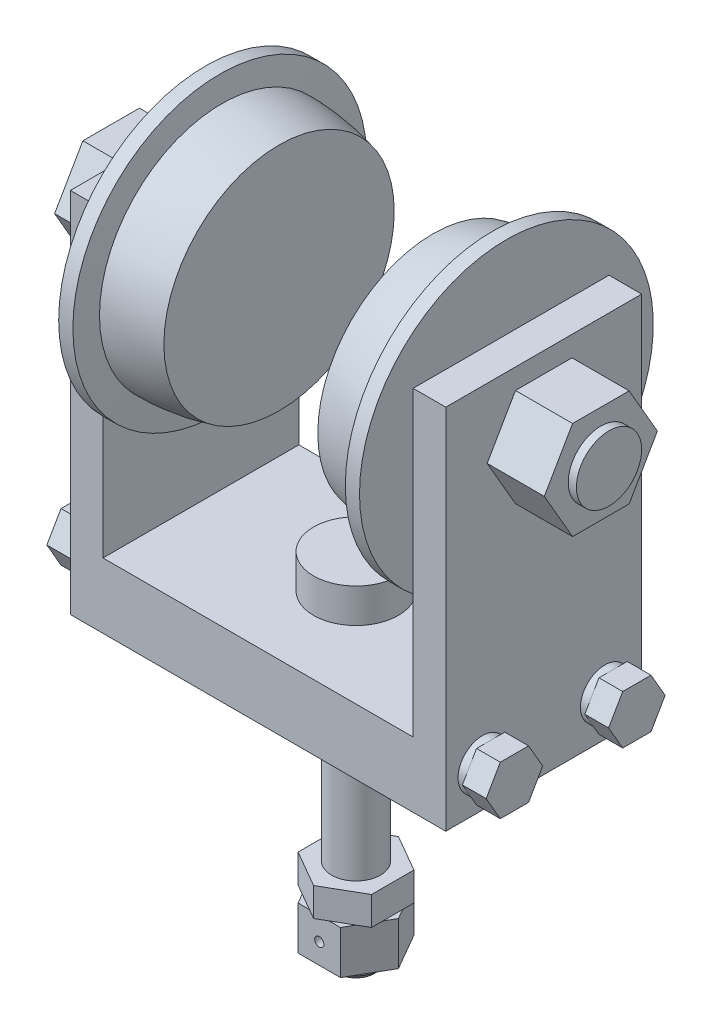
from build123d import *

# Parameters (mm, degrees)
YOKE_CROSS_SECTION_W           = 76.2
YOKE_CROSS_SECTION_H           = 25.4
YOKE_DEPTH                     = 60.325
SIDEPLATE_PROFILE_W            = 76.2
SIDEPLATE_PROFILE_H            = 142.875
SIDEPLATE_DEPTH                = 12.7
WHEEL_PIN_NUT_DEPTH            = 22.225
WHEEL_PIN_PROJECTION_PROFILE_R = 12.7
WHEEL_PIN_PROJECTION_DEPTH     = 3.175
LOCKNUTS_PROFILE_R             = 9.525
LOCKNUTS_DEPTH                 = 3.175
SCREWS_DEPTH                   = 9.2456
PROFILE_R                      = 16.4973
KING_BOLT_HEAD_DEPTH           = 13.3096
DIA_R                          = 9.525
KING_BOLT_DEPTH                = 65.589601
KING_BOLT_JAM_NUT_DEPTH        = 11.1125
KING_BOLT_NUT_DEPTH            = 16.891
SKETCH5_R                      = 9.525
EXTENDED_KING_BOLT_DEPTH       = 6.35
CHAMFER1_SIZE                  = 2.38125
COTTER_PIN_HOLE_REACH          = 73.437
SKETCH8_R                      = 1.778


with BuildPart() as part:
    # YOKE CROSS SECTION → YOKE (new body)
    with BuildSketch(Plane(origin=(0, 0, 0), x_dir=(0, 0, -1), z_dir=(1, 0, 0))):
        with Locations((0, 12.7)):
            Rectangle(YOKE_CROSS_SECTION_W, YOKE_CROSS_SECTION_H)
    extrude(amount=YOKE_DEPTH)

    # SIDEPLATE PROFILE → SIDEPLATE (add)
    with BuildSketch(Plane(origin=(60.325, 0, 0), x_dir=(0, 0, -1), z_dir=(1, 0, 0))):
        with Locations((0, 71.4375)):
            Rectangle(SIDEPLATE_PROFILE_W, SIDEPLATE_PROFILE_H)
    extrude(amount=SIDEPLATE_DEPTH)

    # WHEEL PIN NUT PROFILE → WHEEL PIN NUT (add)
    with BuildSketch(Plane(origin=(73.025, 0, 0), x_dir=(0, 0, -1), z_dir=(1, 0, 0))):
        Polygon((21.997045256, 115.8875), (10.998522628, 134.9375), (-10.998522628, 134.9375), (-21.997045256, 115.8875), (-10.998522628, 96.8375), (10.998522628, 96.8375), align=None)
    extrude(amount=WHEEL_PIN_NUT_DEPTH)

    # WHEEL PIN PROJECTION PROFILE → WHEEL PIN PROJECTION (add)
    with BuildSketch(Plane(origin=(95.25, 0, 0), x_dir=(0, 0, -1), z_dir=(1, 0, 0))):
        with Locations((0, 115.8875)):
            Circle(WHEEL_PIN_PROJECTION_PROFILE_R)
    extrude(amount=WHEEL_PIN_PROJECTION_DEPTH)

    # LOCKNUTS PROFILE → LOCKNUTS (add)
    with BuildSketch(Plane(origin=(73.025, 0, 0), x_dir=(0, 0, -1), z_dir=(1, 0, 0))):
        with Locations((-23.8125, 15.563196315)):
            Circle(LOCKNUTS_PROFILE_R)
    locknuts = extrude(amount=LOCKNUTS_DEPTH)

    # SCREWS PROFILE → SCREWS (add)
    with BuildSketch(Plane(origin=(76.2, 0, 0), x_dir=(0, 0, -1), z_dir=(1, 0, 0))):
        Polygon((-12.813977372, 15.563196315), (-18.313238686, 25.088196315), (-29.311761314, 25.088196315), (-34.811022628, 15.563196315), (-29.311761314, 6.038196315), (-18.313238686, 6.038196315), align=None)
    screws = extrude(amount=SCREWS_DEPTH)

    # PROFILE → KING BOLT HEAD (add)
    with BuildSketch(Plane(origin=(0, 25.4, 0), x_dir=(-1, 0, 0), z_dir=(0, 1, 0))):
        with Locations(Location((0, 0, 0), (0, 0, 90))):  # turned: the seam where the file's is
            Circle(PROFILE_R)
    extrude(amount=KING_BOLT_HEAD_DEPTH)

    # Mirror1: LOCKNUTS, SCREWS across plane
    add(locknuts.mirror(Plane.XY))
    add(screws.mirror(Plane.XY))

    # Mirror5: part across plane


with BuildPart() as part_1:
    add(part.part)
    add(part.part.mirror(Plane(origin=(0, 0, 0), x_dir=(0, 0, 1), z_dir=(1, 0, 0))))

    # DIA. → KING BOLT (add)
    with BuildSketch(Plane.XZ):
        with Locations(Location((0, 0, 0), (0, 0, 90))):  # turned: the seam where the file's is
            Circle(DIA_R)
    extrude(amount=KING_BOLT_DEPTH)

    # KING BOLT JAN NUT PROFILE → KING BOLT JAM NUT (add)
    with BuildSketch(Plane.XZ.offset(65.589600888)):
        Polygon((0, -16.497783942), (14.2875, -8.248891971), (14.2875, 8.248891971), (0, 16.497783942), (-14.2875, 8.248891971), (-14.2875, -8.248891971), align=None)
    extrude(amount=KING_BOLT_JAM_NUT_DEPTH)

    # KING BOLT NUT PROFILE → KING BOLT NUT (add)
    with BuildSketch(Plane.XZ.offset(76.702100888)):
        Polygon((16.497783942, 0), (8.248891971, 14.2875), (-8.248891971, 14.2875), (-16.497783942, 0), (-8.248891971, -14.2875), (8.248891971, -14.2875), align=None)
    extrude(amount=KING_BOLT_NUT_DEPTH)

    # Sketch5 → EXTENDED KING BOLT (add)
    with BuildSketch(Plane.XZ.offset(93.593100888)):
        with Locations(Location((0, 0, 0), (0, 0, 90))):  # turned: the seam where the file's is
            Circle(SKETCH5_R)
    extrude(amount=EXTENDED_KING_BOLT_DEPTH)

    # Chamfer1
    chamfer1_edges = [part_1.edges().sort_by_distance(p)[0] for p in [
        (0, -99.943100888, -9.525),
    ]]
    chamfer(chamfer1_edges, length=CHAMFER1_SIZE)

    # Sketch7 → WHEEL (revolve)
    with BuildSketch(Plane.XY, mode=Mode.PRIVATE) as wheel_sk:
        with BuildLine():
            Line((29.93325323, 160.689554869), (29.93325323, 115.8875))
            Line((29.93325323, 115.8875), (60.325, 115.8875))
            Line((60.325, 115.8875), (60.325, 131.7625))
            Line((60.325, 131.7625), (58.50825323, 131.7625))
            Line((58.50825323, 131.7625), (58.50825323, 173.0375))
            Line((58.50825323, 173.0375), (52.99158275, 173.0375))
            Line((52.99158275, 173.0375), (52.15825323, 163.5125))
            ThreePointArc((52.15825323, 163.5125), (40.956471628, 162.803939998), (29.93325323, 160.689554869))
        make_face()
    wheel = revolve(wheel_sk.sketch.rotate(Axis((29.93325323, 115.8875, 0), (1, 0, 0)), 90), axis=Axis((29.93325323, 115.8875, 0), (1, 0, 0)))  # turned: the seam where the file's is

    # Mirror6: WHEEL across plane
    add(wheel.mirror(Plane(origin=(0, 0, 0), x_dir=(0, 0, 1), z_dir=(1, 0, 0))))

    # Sketch8 → COTTER PIN HOLE (cut, up to next)
    with BuildSketch(Plane.XY.offset(14.2875), mode=Mode.PRIVATE) as cotter_pin_hole_sk1:
        with Locations((0, -85.655600888)):
            Circle(SKETCH8_R)
    cotter_pin_hole_tool1 = extrude(cotter_pin_hole_sk1.sketch, amount=-COTTER_PIN_HOLE_REACH, mode=Mode.PRIVATE) & part_1.part
    add(cotter_pin_hole_tool1.solids().sort_by_distance((0, -85.655601, 14.2875))[0], mode=Mode.SUBTRACT)


solid = part_1.part
